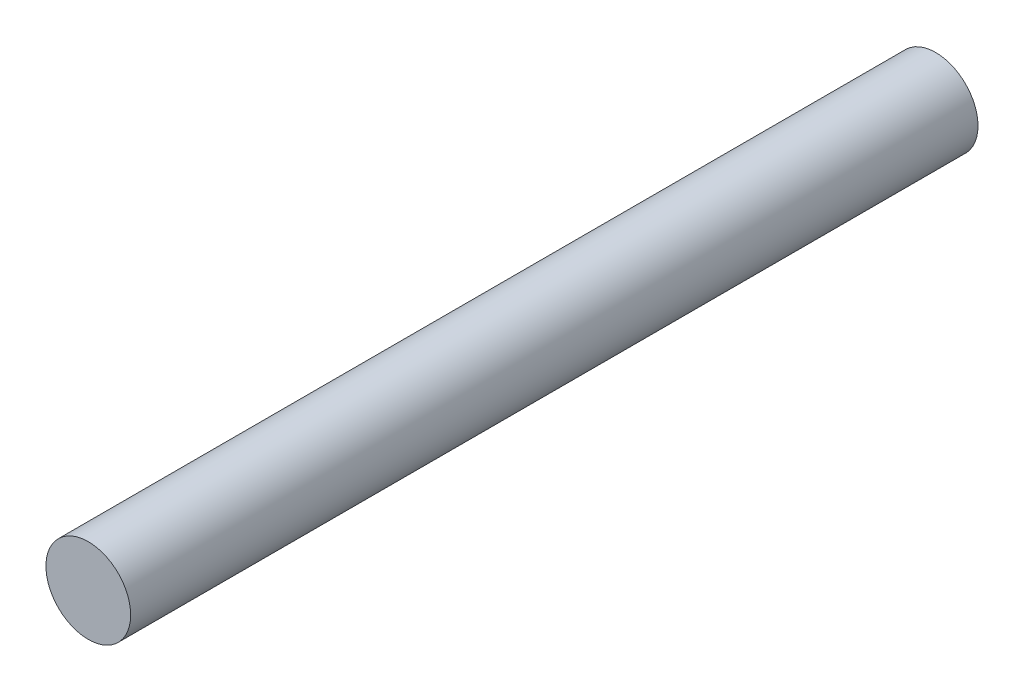
from build123d import *

# Parameters (mm, degrees)
SKETCH1_R           = 2
BOSS_EXTRUDE1_DEPTH = 40


with BuildPart() as part:
    # Sketch1 → Boss-Extrude1 (new body)
    with BuildSketch(Plane.XY):
        Circle(SKETCH1_R)
    extrude(amount=BOSS_EXTRUDE1_DEPTH)


solid = part.part
